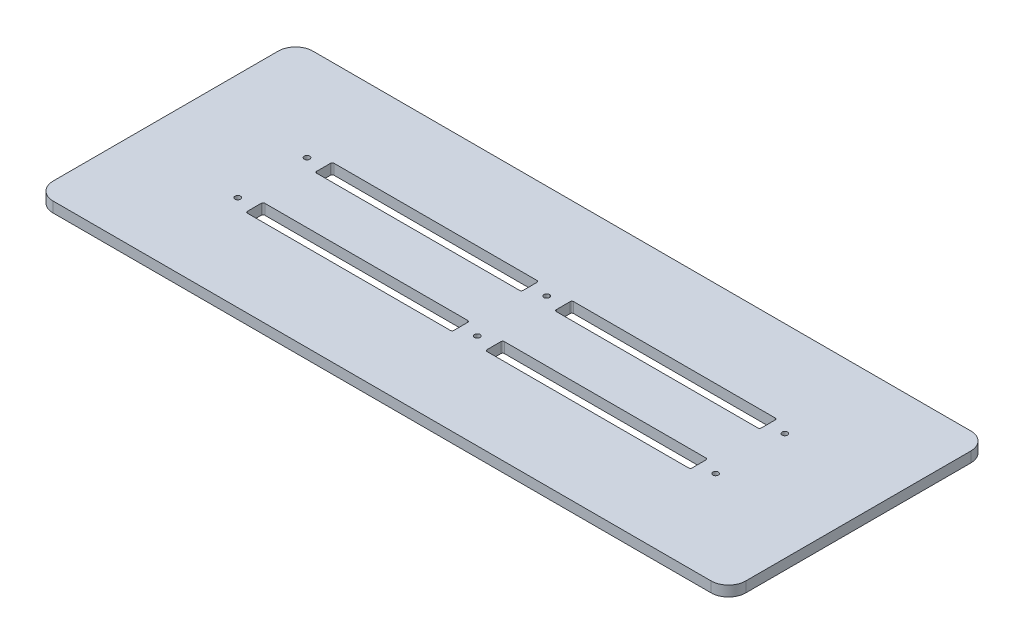
from build123d import *

# Parameters (mm, degrees)
IZIM1_W                     = 400
IZIM1_H                     = 150
IZIM1_W_2                   = 119.18
IZIM1_H_2                   = 10
IZIM1_W_3                   = 118.39
Y_KSEKLIK_EKSTR_ZYON1_DEPTH = 6
RADYUS1_R                   = 10
RADYUS2_R                   = 1
IZIM2_R                     = 1.575
KES_EKSTR_ZYON1_DEPTH       = 7


with BuildPart() as part:
    # Çizim1 → Yükseklik-Ekstrüzyon1 (new body)
    with BuildSketch(Plane(origin=(0, 0, 0), x_dir=(1, 0, 0), z_dir=(0, 1, 0))):
        Rectangle(IZIM1_W, IZIM1_H)
        with Locations((-69.19, 20)):
            Rectangle(IZIM1_W_2, IZIM1_H_2, mode=Mode.SUBTRACT)
        with Locations((68.795, 20)):
            Rectangle(IZIM1_W_3, IZIM1_H_2, mode=Mode.SUBTRACT)
        with Locations((68.795, -20)):
            Rectangle(IZIM1_W_3, IZIM1_H_2, mode=Mode.SUBTRACT)
        with Locations((-69.19, -20)):
            Rectangle(IZIM1_W_2, IZIM1_H_2, mode=Mode.SUBTRACT)
    extrude(amount=-Y_KSEKLIK_EKSTR_ZYON1_DEPTH)

    # Radyus1
    radyus1_edges = [part.edges().sort_by_distance(p)[0] for p in [
        (200, -3, 75),
        (-200, -3, 75),
        (-200, -3, -75),
        (200, -3, -75),
    ]]
    fillet(radyus1_edges, radius=RADYUS1_R)

    # Radyus2
    radyus2_edges = [part.edges().sort_by_distance(p)[0] for p in [
        (9.6, -3, -15),
        (9.6, -3, -25),
        (127.99, -3, -25),
        (127.99, -3, -15),
        (-9.6, -3, -25),
        (-9.6, -3, -15),
        (-128.78, -3, -15),
        (-128.78, -3, -25),
        (127.99, -3, 15),
        (127.99, -3, 25),
        (9.6, -3, 25),
        (9.6, -3, 15),
        (-9.6, -3, 15),
        (-9.6, -3, 25),
        (-128.78, -3, 25),
        (-128.78, -3, 15),
    ]]
    fillet(radyus2_edges, radius=RADYUS2_R)

    # Çizim2 → Kes-Ekstrüzyon1 (cut, through all)
    with BuildSketch(Plane.XZ.offset(6)):
        with Locations((-138.38, 20)):
            Circle(IZIM2_R)
        with Locations((-138.38, -20)):
            Circle(IZIM2_R)
        with Locations((0, -20)):
            Circle(IZIM2_R)
        with Locations((0, 20)):
            Circle(IZIM2_R)
        with Locations((137.59, 20)):
            Circle(IZIM2_R)
        with Locations((137.59, -20)):
            Circle(IZIM2_R)
    extrude(amount=-KES_EKSTR_ZYON1_DEPTH, mode=Mode.SUBTRACT)


solid = part.part
